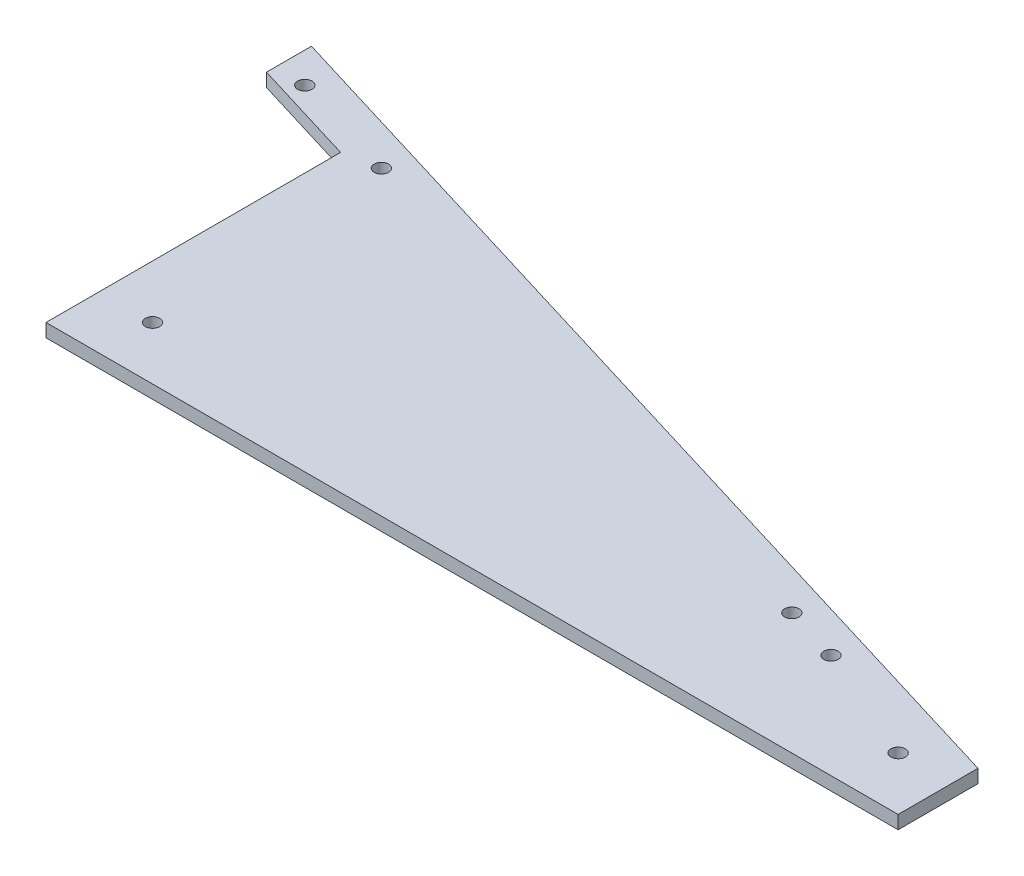
from build123d import *

# Parameters (mm, degrees)
SKETCH1_R           = 3.429
BOSS_EXTRUDE1_DEPTH = 6.35
BOSS_EXTRUDE2_DEPTH = 6.35
CUT_EXTRUDE1_REACH  = 8.35
SKETCH3_R           = 3.429


with BuildPart() as part:
    # Sketch1 → Boss-Extrude1 (new body)
    with BuildSketch(Plane(origin=(0, 0, 0), x_dir=(1, 0, 0), z_dir=(0, 1, 0))):
        Polygon((0, 0), (406.4, 0), (406.4, 38.1), (0, 161.925), align=None)
        with Locations((381, 25.4)):
            Circle(SKETCH1_R, mode=Mode.SUBTRACT)
        with Locations((25.4, 25.4)):
            Circle(SKETCH1_R, mode=Mode.SUBTRACT)
    extrude(amount=BOSS_EXTRUDE1_DEPTH)

    # Sketch2 → Boss-Extrude2 (add)
    with BuildSketch(Plane(origin=(0, 6.35, 0), x_dir=(1, 0, 0), z_dir=(0, 1, 0))):
        Polygon((0, 161.925), (-50.8, 177.403125), (-50.8, 155.961232961), (0, 140.483107961), align=None)
    extrude(amount=-BOSS_EXTRUDE2_DEPTH)

    # Sketch3 → Cut-Extrude1 (cut, up to next)
    with BuildSketch(Plane(origin=(0, 6.35, 0), x_dir=(1, 0, 0), z_dir=(0, 1, 0)), mode=Mode.PRIVATE) as cut_extrude1_sk1:
        with Locations((324.672621663, 49.724892693)):
            Circle(SKETCH3_R)
    cut_extrude1_tool1 = extrude(cut_extrude1_sk1.sketch, amount=-CUT_EXTRUDE1_REACH, mode=Mode.PRIVATE) & part.part
    add(cut_extrude1_tool1.solids().sort_by_distance((324.672622, 6.35, -49.724893))[0], mode=Mode.SUBTRACT)
    # Sketch3 → Cut-Extrude1 (cut, up to next)
    with BuildSketch(Plane(origin=(0, 6.35, 0), x_dir=(1, 0, 0), z_dir=(0, 1, 0)), mode=Mode.PRIVATE) as cut_extrude1_sk2:
        with Locations((16.261590572, 143.693878729)):
            Circle(SKETCH3_R)
    cut_extrude1_tool2 = extrude(cut_extrude1_sk2.sketch, amount=-CUT_EXTRUDE1_REACH, mode=Mode.PRIVATE) & part.part
    add(cut_extrude1_tool2.solids().sort_by_distance((16.261591, 6.35, -143.693879))[0], mode=Mode.SUBTRACT)
    # Sketch3 → Cut-Extrude1 (cut, up to next)
    with BuildSketch(Plane(origin=(0, 6.35, 0), x_dir=(1, 0, 0), z_dir=(0, 1, 0)), mode=Mode.PRIVATE) as cut_extrude1_sk3:
        with Locations((297.810987833, 57.909296751)):
            Circle(SKETCH3_R)
    cut_extrude1_tool3 = extrude(cut_extrude1_sk3.sketch, amount=-CUT_EXTRUDE1_REACH, mode=Mode.PRIVATE) & part.part
    add(cut_extrude1_tool3.solids().sort_by_distance((297.810988, 6.35, -57.909297))[0], mode=Mode.SUBTRACT)
    # Sketch3 → Cut-Extrude1 (cut, up to next)
    with BuildSketch(Plane(origin=(0, 6.35, 0), x_dir=(1, 0, 0), z_dir=(0, 1, 0)), mode=Mode.PRIVATE) as cut_extrude1_sk4:
        with Locations((-36.278616697, 159.702223131)):
            Circle(SKETCH3_R)
    cut_extrude1_tool4 = extrude(cut_extrude1_sk4.sketch, amount=-CUT_EXTRUDE1_REACH, mode=Mode.PRIVATE) & part.part
    add(cut_extrude1_tool4.solids().sort_by_distance((-36.278617, 6.35, -159.702223))[0], mode=Mode.SUBTRACT)


solid = part.part
